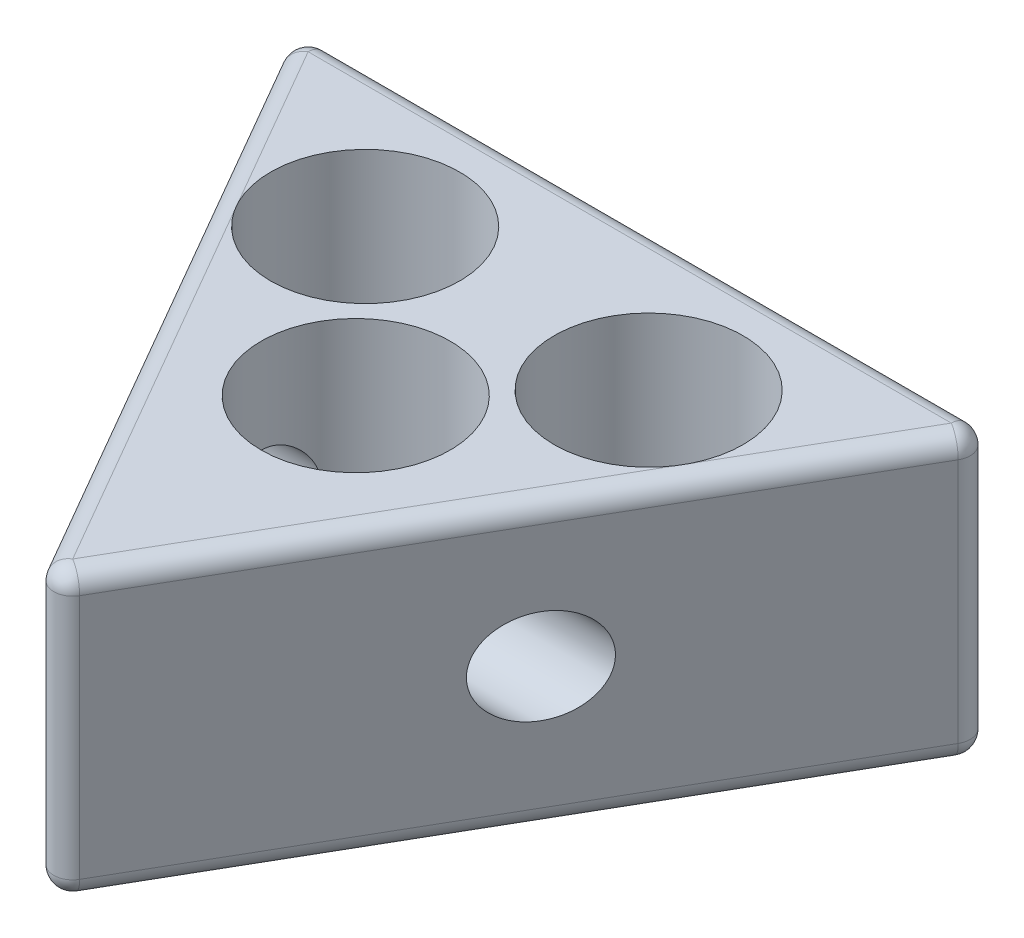
from build123d import *

# Parameters (mm, degrees)
BOSS_EXTRUDE1_DEPTH = 30
FILLET1_R           = 2
SKETCH2_R           = 10
CUT_EXTRUDE3_DEPTH  = 31
SKETCH3_R           = 5
CUT_EXTRUDE4_DEPTH  = 73.07179677


with BuildPart() as part:
    # Sketch1 → Boss-Extrude1 (new body)
    with BuildSketch(Plane(origin=(0, 0, 0), x_dir=(1, 0, 0), z_dir=(0, 1, 0))):
        Polygon((0, 0), (37.5, 64.951905284), (-37.5, 64.951905284), align=None)
    extrude(amount=BOSS_EXTRUDE1_DEPTH)

    # Fillet1
    fillet1_edges = [part.edges().sort_by_distance(p)[0] for p in [
        (0, 30, -64.951905284),
        (0, 0, -64.951905284),
        (-18.75, 30, -32.475952642),
        (18.75, 0, -32.475952642),
        (-18.75, 0, -32.475952642),
        (-37.5, 15, -64.951905284),
        (37.5, 15, -64.951905284),
        (0, 15, 0),
        (18.75, 30, -32.475952642),
    ]]
    fillet(fillet1_edges, radius=FILLET1_R)

    # Sketch2 → Cut-Extrude3 (cut, through all)
    with BuildSketch(Plane(origin=(0, 30, 0), x_dir=(1, 0, 0), z_dir=(0, 1, 0))):
        with Locations((-15, 49.951905284)):
            Circle(SKETCH2_R)
        with Locations((15, 49.951905284)):
            Circle(SKETCH2_R)
        with Locations((0, 33.951905284)):
            Circle(SKETCH2_R)
    extrude(amount=-CUT_EXTRUDE3_DEPTH, mode=Mode.SUBTRACT)

    # Sketch3 → Cut-Extrude4 (cut, through all)
    with BuildSketch(Plane.ZY.offset(36.035898385)):
        with Locations((-33.951905284, 15)):
            Circle(SKETCH3_R)
    extrude(amount=-CUT_EXTRUDE4_DEPTH, mode=Mode.SUBTRACT)


solid = part.part
